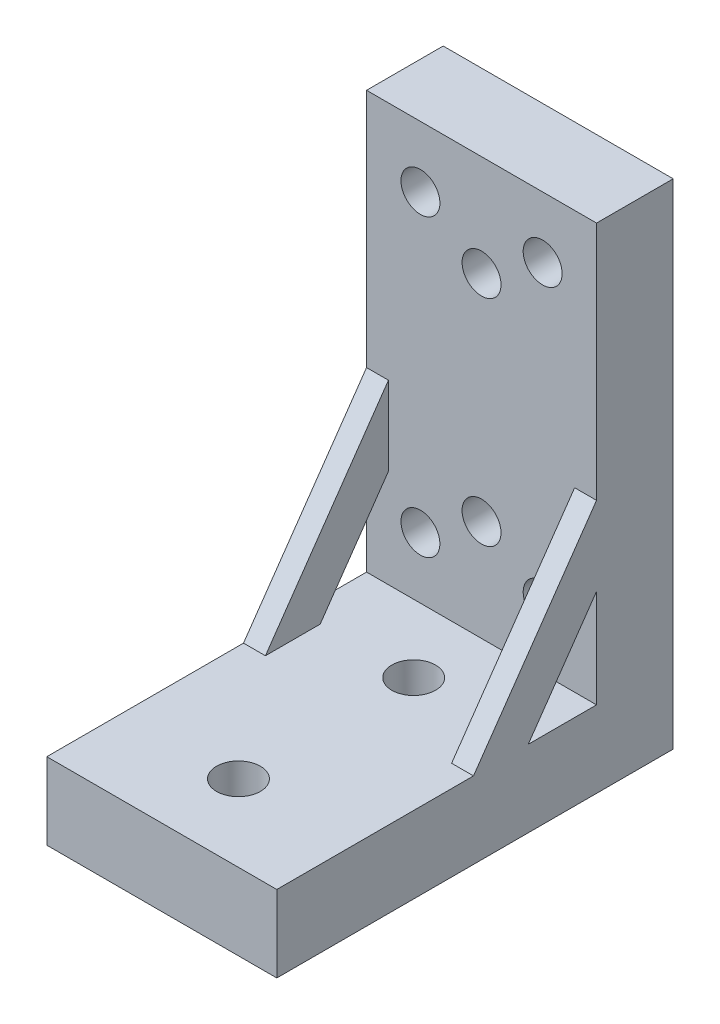
from build123d import *

# Parameters (mm, degrees)
SKETCH1_W           = 21
SKETCH1_H           = 38.1
SKETCH1_R           = 1.778
BOSS_EXTRUDE1_DEPTH = 7
SKETCH3_W           = 21
SKETCH3_H           = 7
BOSS_EXTRUDE2_DEPTH = 36.195
SKETCH4_R           = 2
CUT_EXTRUDE1_DEPTH  = 10.5
BOSS_EXTRUDE3_DEPTH = 2
BOSS_EXTRUDE4_START = -19
BOSS_EXTRUDE4_DEPTH = 2


with BuildPart() as part:
    # Sketch1 → Boss-Extrude1 (new body)
    with BuildSketch(Plane.XY):
        Rectangle(SKETCH1_W, SKETCH1_H)
        with Locations((-5.58, 13.47)):
            Circle(SKETCH1_R, mode=Mode.SUBTRACT)
        with Locations((5.58, 13.47)):
            Circle(SKETCH1_R, mode=Mode.SUBTRACT)
        with Locations((0, 9.805)):
            Circle(SKETCH1_R, mode=Mode.SUBTRACT)
        with Locations((5.58, -13.47)):
            Circle(SKETCH1_R, mode=Mode.SUBTRACT)
        with Locations((0, -9.805)):
            Circle(SKETCH1_R, mode=Mode.SUBTRACT)
        with Locations((-5.58, -13.47)):
            Circle(SKETCH1_R, mode=Mode.SUBTRACT)
    extrude(amount=BOSS_EXTRUDE1_DEPTH)

    # Sketch3 → Boss-Extrude2 (add)
    with BuildSketch(Plane(origin=(0, 0, 0), x_dir=(-1, 0, 0), z_dir=(0, 0, -1))):
        with Locations((0, -22.55)):
            Rectangle(SKETCH3_W, SKETCH3_H)
    extrude(amount=-BOSS_EXTRUDE2_DEPTH)

    # Sketch4 → Cut-Extrude1 (cut)
    with BuildSketch(Plane.XZ.offset(26.05)):
        with Locations((0, 13.195)):
            Circle(SKETCH4_R)
        with Locations((0, 29.195)):
            Circle(SKETCH4_R)
    extrude(amount=-CUT_EXTRUDE1_DEPTH, mode=Mode.SUBTRACT)

    # Sketch5 → Boss-Extrude3 (add)
    with BuildSketch(Plane(origin=(10.5, 0, 0), x_dir=(0, 0, -1), z_dir=(1, 0, 0))):
        Polygon((-18.0975, -26.05), (0, 0), (0, 7.197126675), (-23.0975, -26.05), align=None)
    extrude(amount=-BOSS_EXTRUDE3_DEPTH)

    # Sketch5_2 → Boss-Extrude4 (add)
    with BuildSketch(Plane(origin=(10.5, 0, 0), x_dir=(0, 0, -1), z_dir=(1, 0, 0)).offset(BOSS_EXTRUDE4_START)):
        Polygon((-18.0975, -26.05), (0, 0), (0, 7.197126675), (-23.0975, -26.05), align=None)
    extrude(amount=-BOSS_EXTRUDE4_DEPTH)


solid = part.part
